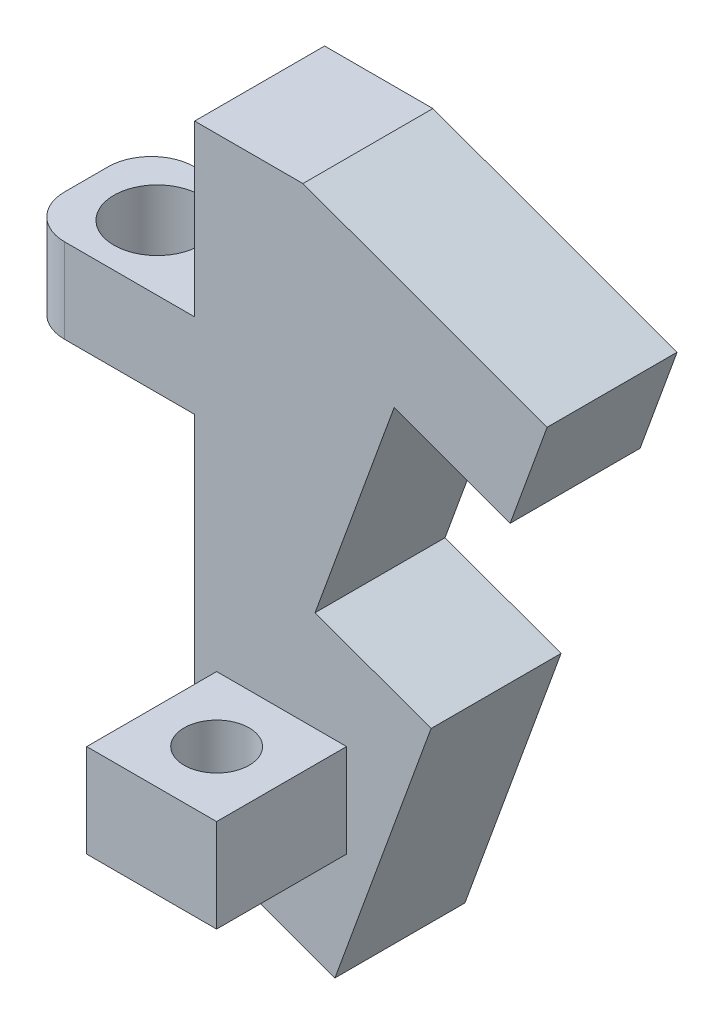
from build123d import *

# Parameters (mm, degrees)
BOSS_EXTRUDE1_DEPTH = 6
SKETCH2_W           = 6
SKETCH2_H           = 3.9
BOSS_EXTRUDE2_DEPTH = 8
SKETCH3_R           = 2
CUT_EXTRUDE2_DEPTH  = 24.194962869
FILLET1_R           = 2
SKETCH6_W           = 5.996508816
SKETCH6_H           = 4.3
BOSS_EXTRUDE4_DEPTH = 6
SKETCH7_R           = 1.5
CUT_EXTRUDE3_DEPTH  = 26.803718238


with BuildPart() as part:
    # Sketch1 → Boss-Extrude1 (new body)
    with BuildSketch(Plane.XY):
        Polygon((-31.610053316, -13.34695045), (-31.610053316, -34.17695045), (-31.610053316, -42.01579246), (-25.132618973, -44.373385755), (-20.693197512, -32.176175537), (-26.049445451, -30.226660721), (-22.400090521, -20.200140457), (-17.043842583, -22.149655274), (-15.333741866, -17.45119217), (-26.610053316, -13.34695045), align=None)
    extrude(amount=BOSS_EXTRUDE1_DEPTH)

    # Sketch2 → Boss-Extrude2 (add)
    with BuildSketch(Plane.ZY.offset(31.610053316)):
        with Locations((3, -23.128422886)):
            Rectangle(SKETCH2_W, SKETCH2_H)
    extrude(amount=BOSS_EXTRUDE2_DEPTH)

    # Sketch3 → Cut-Extrude2 (cut, through all)
    with BuildSketch(Plane(origin=(0, -21.178422886, 0), x_dir=(1, 0, 0), z_dir=(0, 1, 0))):
        with Locations((-36.339467267, -3)):
            Circle(SKETCH3_R)
    extrude(amount=-CUT_EXTRUDE2_DEPTH, mode=Mode.SUBTRACT)

    # Fillet1
    fillet1_edges = [part.edges().sort_by_distance(p)[0] for p in [
        (-39.610053316, -23.128422886, 0),
        (-39.610053316, -23.128422886, 6),
    ]]
    fillet(fillet1_edges, radius=FILLET1_R)

    # Sketch6 → Boss-Extrude4 (add)
    with BuildSketch(Plane.XY.offset(6)):
        with Locations((-27.594946536, -37.000668688)):
            Rectangle(SKETCH6_W, SKETCH6_H)
    extrude(amount=BOSS_EXTRUDE4_DEPTH)

    # Sketch7 → Cut-Extrude3 (cut, through all)
    with BuildSketch(Plane.XZ.offset(39.150668688)):
        with Locations((-27.594946536, 9)):
            Circle(SKETCH7_R)
    extrude(amount=-CUT_EXTRUDE3_DEPTH, mode=Mode.SUBTRACT)


solid = part.part
